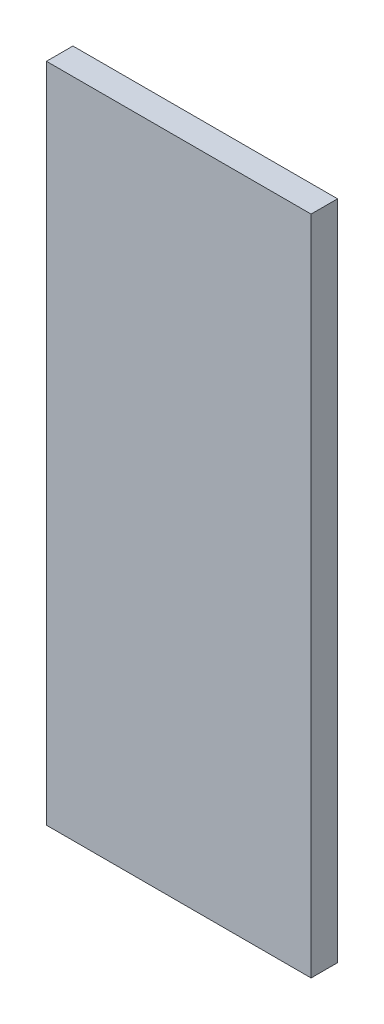
from build123d import *

# Parameters (mm, degrees)
SKETCH_1_W      = 12
SKETCH_1_H      = 30
EXTRUDE_1_DEPTH = 1.2
SKETCH_5_W      = 4
SKETCH_5_H      = 5
EXTRUDE_3_DEPTH = 2


with BuildPart() as part:
    # 草图1 → 凸台-拉伸1 (new body)
    with BuildSketch(Plane.XY):
        Rectangle(SKETCH_1_W, SKETCH_1_H)
    extrude(amount=EXTRUDE_1_DEPTH)

    # 草图5 → 凸台-拉伸3 (add)
    with BuildSketch(Plane(origin=(0, 0, 0), x_dir=(-1, 0, 0), z_dir=(0, 0, -1))):
        Rectangle(SKETCH_5_W, SKETCH_5_H)
    extrude(amount=EXTRUDE_3_DEPTH)


solid = part.part
